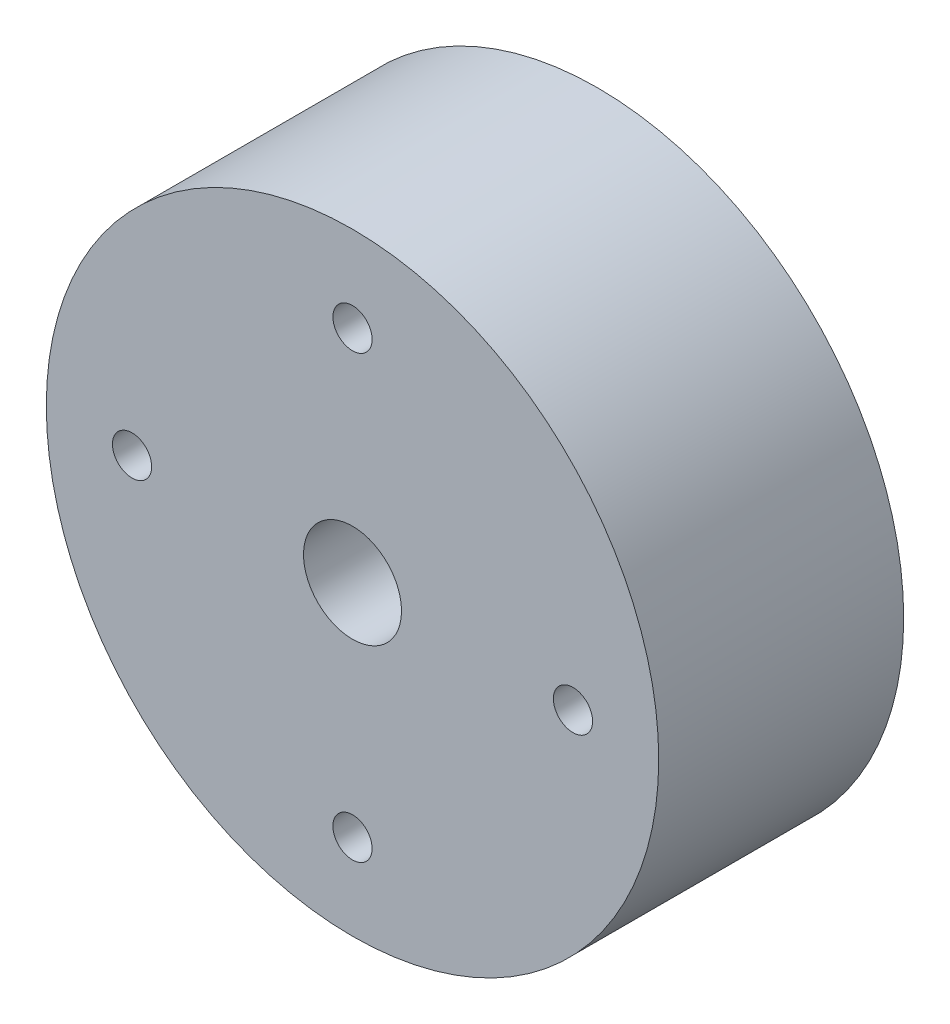
from build123d import *

# Parameters (mm, degrees)
SKETCH1_R           = 25
SKETCH1_R_2         = 4
BOSS_EXTRUDE2_DEPTH = 20
SKETCH2_R           = 1.6
CUT_EXTRUDE1_DEPTH  = 10


with BuildPart() as part:
    # Sketch1 → Boss-Extrude2 (new body)
    with BuildSketch(Plane.XY):
        Circle(SKETCH1_R)
        Circle(SKETCH1_R_2, mode=Mode.SUBTRACT)
    extrude(amount=BOSS_EXTRUDE2_DEPTH)

    # Sketch2 → Cut-Extrude1 (cut)
    with BuildSketch(Plane.XY.offset(20)):
        with Locations((0, 18)):
            Circle(SKETCH2_R)
        with Locations((18, 0)):
            Circle(SKETCH2_R)
        with Locations((0, -18)):
            Circle(SKETCH2_R)
        with Locations((-18, 0)):
            Circle(SKETCH2_R)
    extrude(amount=-CUT_EXTRUDE1_DEPTH, mode=Mode.SUBTRACT)


solid = part.part
